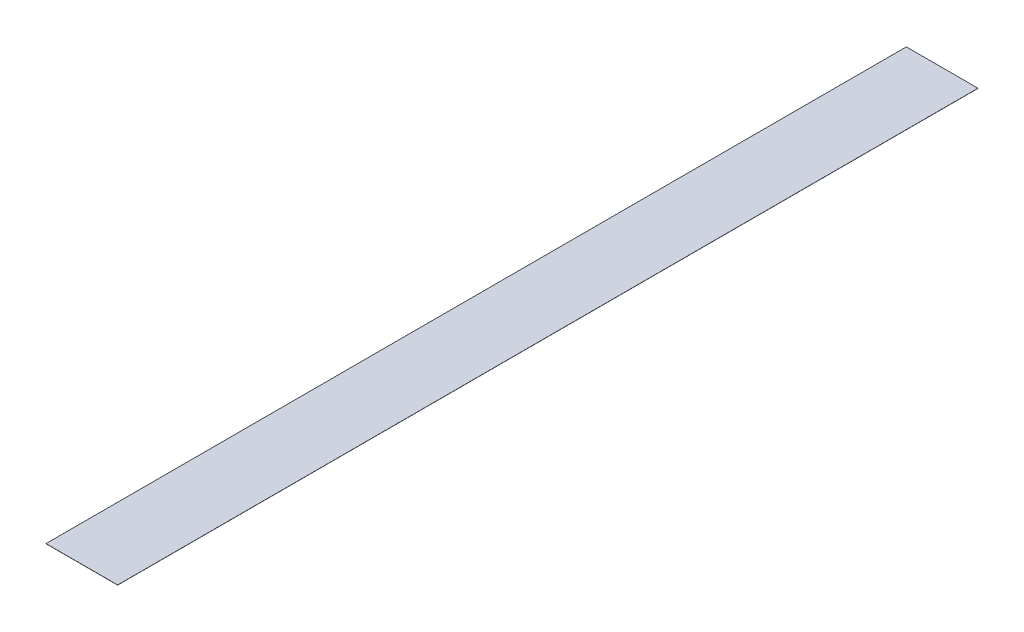
from build123d import *

# Parameters (mm, degrees)
SKETCH1_W      = 24.9
SKETCH1_H      = 299
EXTRUDE1_DEPTH = 0.0508


with BuildPart() as part:
    # Sketch1 → Extrude1 (new body)
    with BuildSketch(Plane(origin=(0, 0, 0), x_dir=(1, 0, 0), z_dir=(0, 1, 0))):
        Rectangle(SKETCH1_W, SKETCH1_H)
    extrude(amount=EXTRUDE1_DEPTH)


solid = part.part
